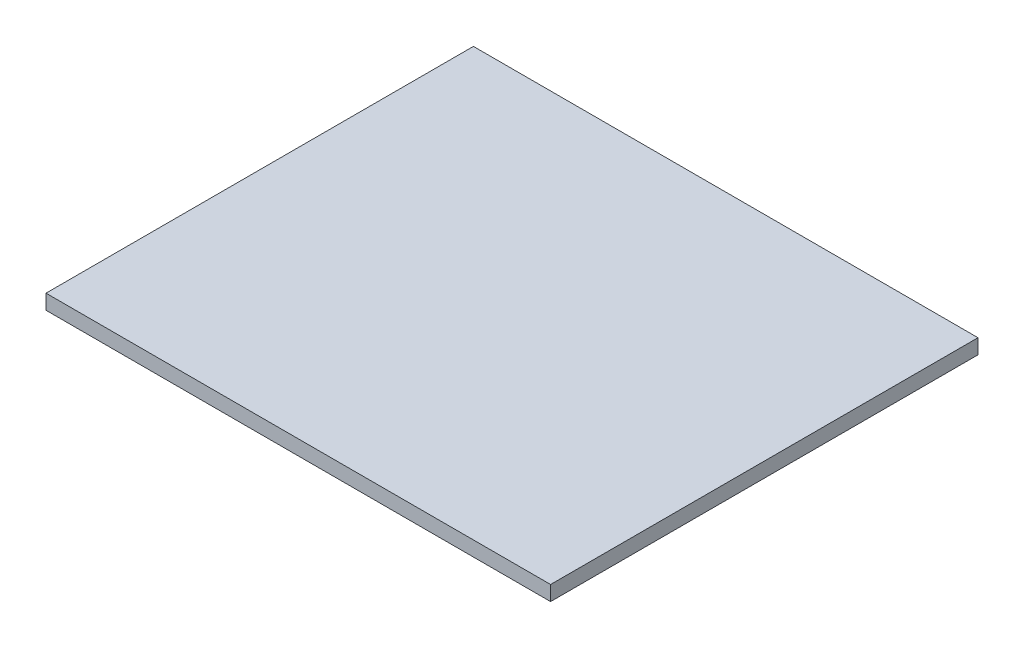
from build123d import *

# Parameters (mm, degrees)
SKETCH1_W           = 215.9
SKETCH1_H           = 182.88
BOSS_EXTRUDE1_DEPTH = 6.35


with BuildPart() as part:
    # Sketch1 → Boss-Extrude1 (new body)
    with BuildSketch(Plane(origin=(0, 0, 0), x_dir=(1, 0, 0), z_dir=(0, 1, 0))):
        Rectangle(SKETCH1_W, SKETCH1_H)
    extrude(amount=BOSS_EXTRUDE1_DEPTH)


solid = part.part
